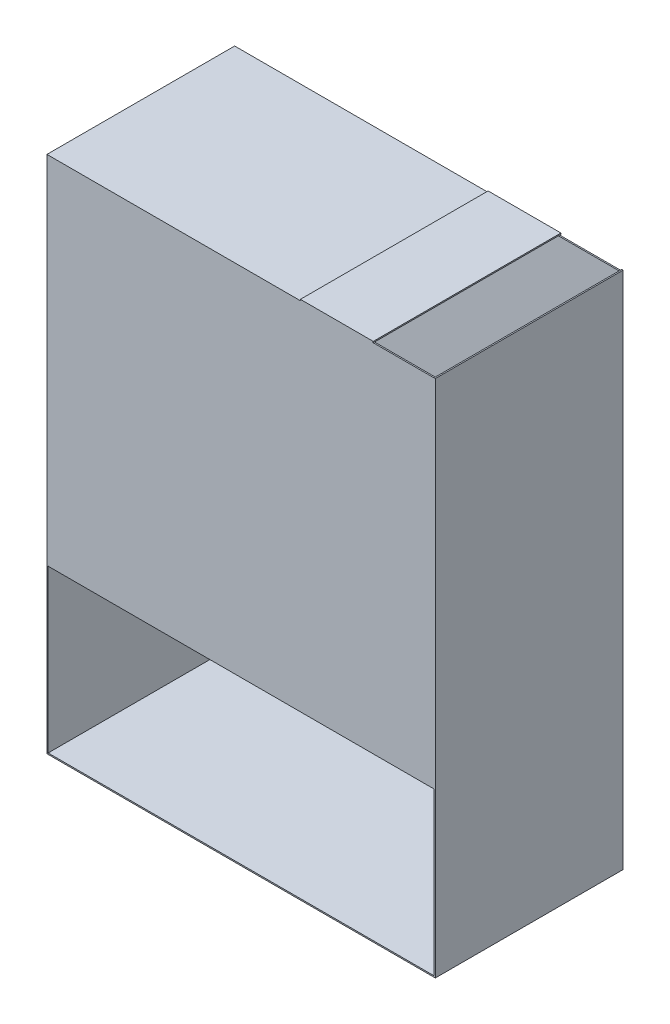
from build123d import *

# Parameters (mm, degrees)
EXTRUDE_1_DEPTH = 290
SKETCH_2_W      = 598
SKETCH_2_H      = 2
EXTRUDE_2_DEPTH = 800
EXTRUDE_START   = 801.875465
SKETCH_3_W      = 600
SKETCH_3_H      = 2
EXTRUDE_3_DEPTH = 550


with BuildPart() as part:
    # 草图1 → 凸台-拉伸1 (new body)
    with BuildSketch(Plane.XY):
        Polygon((0, 801.875465042), (1.875465042, 801.875465042), (391.533669143, 801.875465042), (391.533669143, 803.750930084), (504.06157166, 803.750930084), (504.06157166, 801.875465042), (451.987075109, 801.875465042), (451.987075109, 800), (1.875465042, 800), (1.875465042, 2), (598, 2), (598, 802), (600, 802), (600, 1.871806921), (600, 0), (0, 0), (0, 1.875465042), align=None)
    extrude(amount=EXTRUDE_1_DEPTH)

    # 草图2 → 凸台-拉伸2 (add)
    with BuildSketch(Plane(origin=(0, 0, 0), x_dir=(1, 0, 0), z_dir=(0, 1, 0))):
        with Locations((299, -1)):
            Rectangle(SKETCH_2_W, SKETCH_2_H)
    extrude(amount=EXTRUDE_2_DEPTH)

    # 草图3 → 凸台-拉伸3 (add)
    with BuildSketch(Plane(origin=(0, 0, 0), x_dir=(1, 0, 0), z_dir=(0, 1, 0)).offset(EXTRUDE_START)):
        with Locations((300, -289)):
            Rectangle(SKETCH_3_W, SKETCH_3_H)
    extrude(amount=-EXTRUDE_3_DEPTH)


solid = part.part
